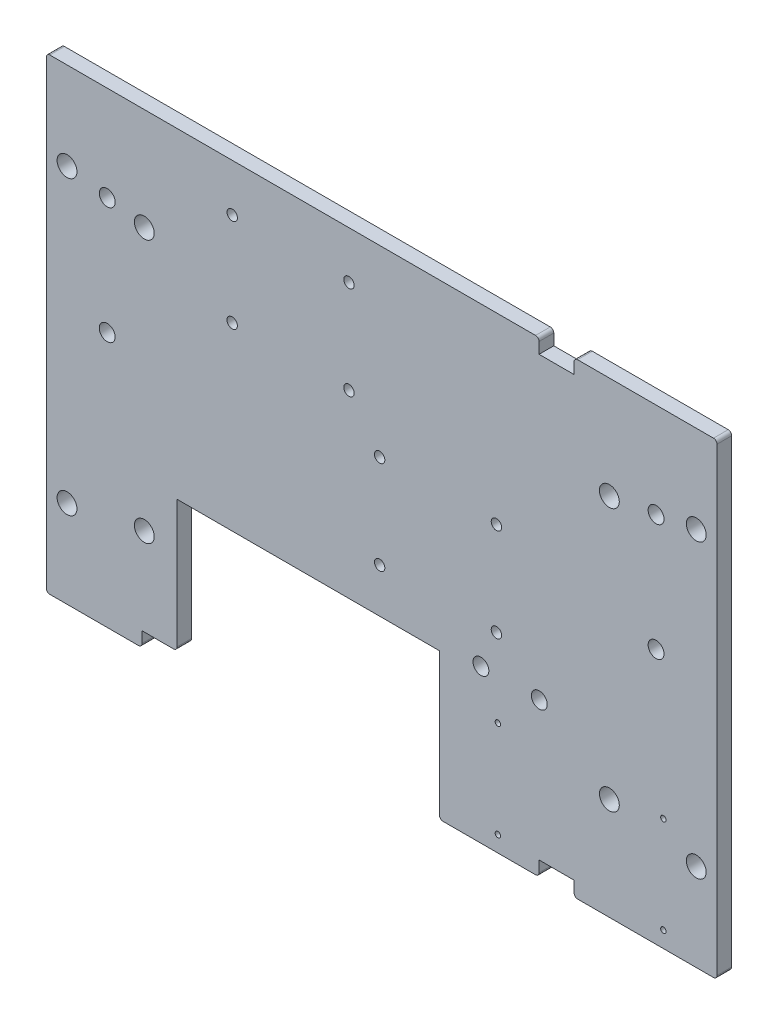
from build123d import *

# Parameters (mm, degrees)
SKETCH1_W           = 145.885353282
SKETCH1_H           = 101.6
BOSS_EXTRUDE1_DEPTH = 3.2004
SKETCH4_W           = 57.100000132
SKETCH4_H           = 31.75
CUT_EXTRUDE1_DEPTH  = 3.2004
SKETCH5_R           = 2.159
CUT_EXTRUDE2_DEPTH  = 3.2004
SKETCH7_R           = 1.1303
CUT_EXTRUDE3_DEPTH  = 3.2004
SKETCH9_W           = 7.62
SKETCH9_H           = 3.175
CUT_EXTRUDE5_DEPTH  = 3.2004
SKETCH10_R          = 0.59563
CUT_EXTRUDE6_DEPTH  = 3.2004
FILLET1_R           = 0.762
SKETCH11_R          = 1.7272
CUT_EXTRUDE7_DEPTH  = 3.2004


with BuildPart() as part:
    # Sketch1 → Boss-Extrude1 (new body)
    with BuildSketch(Plane.XY):
        with Locations((72.942676641, 50.8)):
            Rectangle(SKETCH1_W, SKETCH1_H)
    extrude(amount=BOSS_EXTRUDE1_DEPTH)

    # Sketch4 → Cut-Extrude1 (cut)
    with BuildSketch(Plane.XY.offset(3.2004)):
        with Locations((56.982760066, 15.875)):
            Rectangle(SKETCH4_W, SKETCH4_H)
    extrude(amount=-CUT_EXTRUDE1_DEPTH, mode=Mode.SUBTRACT)

    # Sketch5 → Cut-Extrude2 (cut)
    with BuildSketch(Plane.XY.offset(3.2004)):
        with Locations((141.376853282, 82.55)):
            Circle(SKETCH5_R)
        with Locations((141.376853282, 19.05)):
            Circle(SKETCH5_R)
        with Locations((4.5085, 19.05)):
            Circle(SKETCH5_R)
        with Locations((4.5085, 82.55)):
            Circle(SKETCH5_R)
        with Locations((21.31994339, 79.375)):
            Circle(SKETCH5_R)
        with Locations((21.31994339, 22.225)):
            Circle(SKETCH5_R)
        with Locations((122.472903282, 79.375)):
            Circle(SKETCH5_R)
        with Locations((122.472903282, 22.225)):
            Circle(SKETCH5_R)
    extrude(amount=-CUT_EXTRUDE2_DEPTH, mode=Mode.SUBTRACT)

    # Sketch7 → Cut-Extrude3 (cut)
    with BuildSketch(Plane(origin=(0, 0, 0), x_dir=(-1, 0, 0), z_dir=(0, 0, -1))):
        with Locations((-40.438191852, 91.294483225)):
            Circle(SKETCH7_R)
        with Locations((-40.438191852, 70.974483225)):
            Circle(SKETCH7_R)
        with Locations((-65.838191852, 70.974483225)):
            Circle(SKETCH7_R)
        with Locations((-65.838191852, 91.294483225)):
            Circle(SKETCH7_R)
        with Locations((-72.507486221, 61.720086416)):
            Circle(SKETCH7_R)
        with Locations((-72.507486221, 41.400086416)):
            Circle(SKETCH7_R)
        with Locations((-97.907486221, 41.400086416)):
            Circle(SKETCH7_R)
        with Locations((-97.907486221, 61.720086416)):
            Circle(SKETCH7_R)
    extrude(amount=-CUT_EXTRUDE3_DEPTH, mode=Mode.SUBTRACT)

    # Sketch9 → Cut-Extrude5 (cut)
    with BuildSketch(Plane.XY.offset(3.2004)):
        with Locations((110.993373282, 100.0125)):
            Rectangle(SKETCH9_W, SKETCH9_H)
        with Locations((110.993373282, 1.5875)):
            Rectangle(SKETCH9_W, SKETCH9_H)
        with Locations((24.62276, 1.5875)):
            Rectangle(SKETCH9_W, SKETCH9_H)
    extrude(amount=-CUT_EXTRUDE5_DEPTH, mode=Mode.SUBTRACT)

    # Sketch10 → Cut-Extrude6 (cut)
    with BuildSketch(Plane.XY.offset(3.2004)):
        with Locations((98.232760132, 24.47)):
            Circle(SKETCH10_R)
        with Locations((134.232760132, 24.47)):
            Circle(SKETCH10_R)
        with Locations((98.232760132, 3.47)):
            Circle(SKETCH10_R)
        with Locations((134.232760132, 3.47)):
            Circle(SKETCH10_R)
    extrude(amount=-CUT_EXTRUDE6_DEPTH, mode=Mode.SUBTRACT)

    # Fillet1
    fillet1_edges = [part.edges().sort_by_distance(p)[0] for p in [
        (114.803373282, 101.6, 1.6002),
        (107.183373282, 101.6, 1.6002),
        (114.803373282, 0, 1.6002),
        (107.183373282, 0, 1.6002),
        (28.43276, 3.175, 1.6002),
        (20.81276, 0, 1.6002),
        (85.532760132, 0, 1.6002),
        (0, 101.6, 1.6002),
        (145.885353282, 101.6, 1.6002),
        (145.885353282, 0, 1.6002),
        (0, 0, 1.6002),
    ]]
    fillet(fillet1_edges, radius=FILLET1_R)

    # Sketch11 → Cut-Extrude7 (cut)
    with BuildSketch(Plane.XY.offset(3.2004)):
        with Locations((13.252676641, 55.5625)):
            Circle(SKETCH11_R)
        with Locations((13.252676641, 80.9625)):
            Circle(SKETCH11_R)
        with Locations((132.632676641, 55.5625)):
            Circle(SKETCH11_R)
        with Locations((132.632676641, 80.9625)):
            Circle(SKETCH11_R)
        with Locations((107.232676641, 33.3375)):
            Circle(SKETCH11_R)
        with Locations((94.532676641, 33.3375)):
            Circle(SKETCH11_R)
    extrude(amount=-CUT_EXTRUDE7_DEPTH, mode=Mode.SUBTRACT)


solid = part.part
